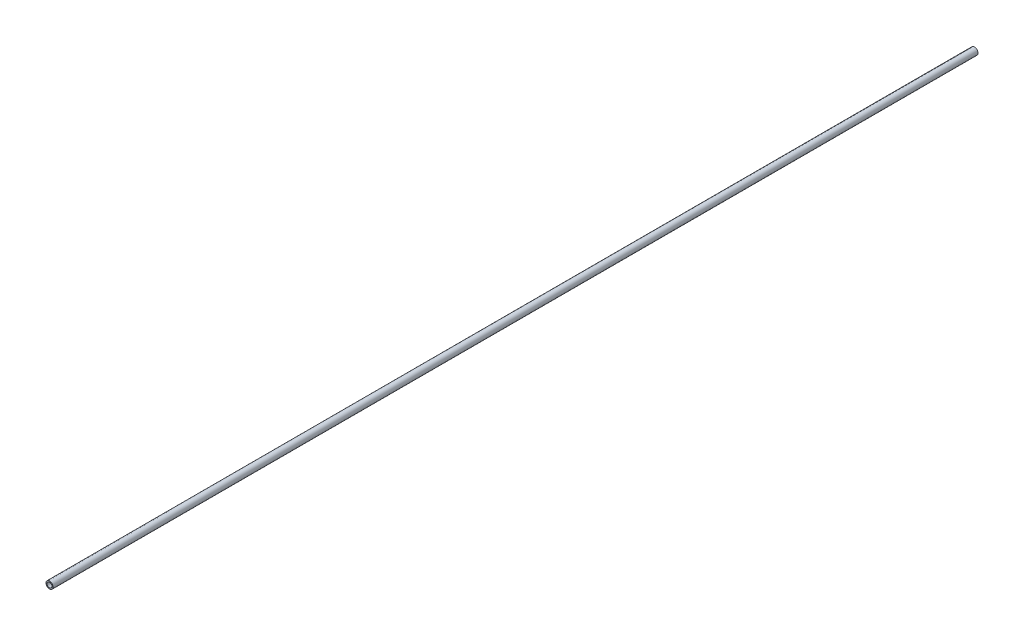
from build123d import *

# Parameters (mm, degrees)
SKETCH1_R           = 6.83635542
SKETCH1_R_2         = 4.83635542
BOSS_EXTRUDE1_DEPTH = 1799.55


with BuildPart() as part:
    # Sketch1 → Boss-Extrude1 (new body)
    with BuildSketch(Plane.XY):
        Circle(SKETCH1_R)
        Circle(SKETCH1_R_2, mode=Mode.SUBTRACT)
    extrude(amount=-BOSS_EXTRUDE1_DEPTH)


solid = part.part
